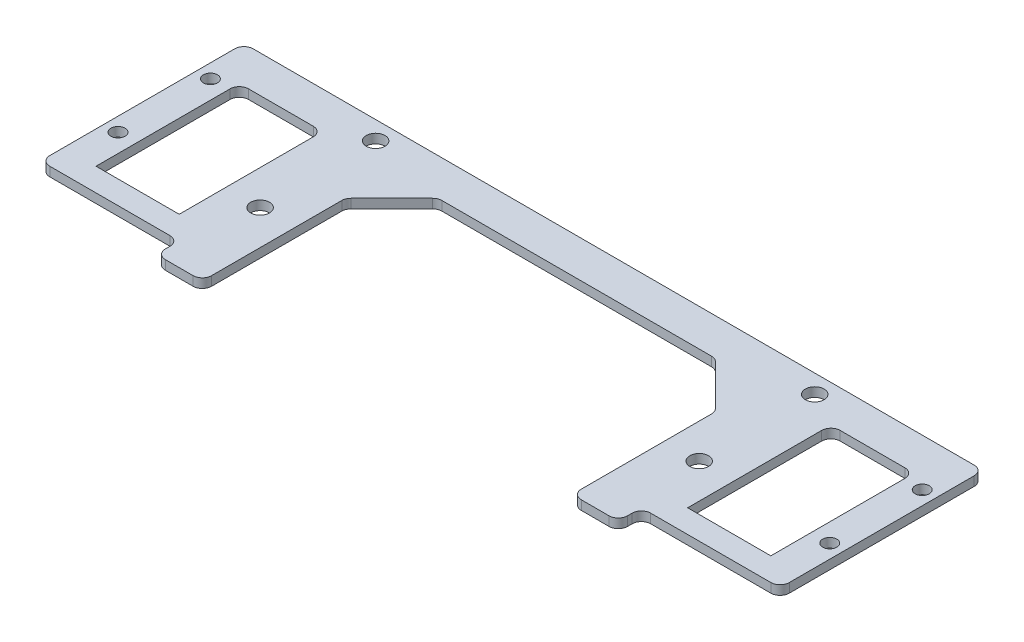
from build123d import *

# Parameters (mm, degrees)
SKETCH_1_W          = 160
SKETCH_1_H          = 49
SKETCH_1_R          = 1.525
SKETCH_1_R_2        = 2.025
EXTRUDE_1_DEPTH     = 2
SKETCH_2_W          = 80
SKETCH_2_H          = 33
SKETCH_2_W_2        = 18
CUT_EXTRUDE_1_DEPTH = 10
CHAMFER_1_SIZE      = 10
FILLET_1_R          = 2
SKETCH_3_W          = 30
SKETCH_3_H          = 5
CUT_EXTRUDE_2_DEPTH = 10
SKETCH_4_W          = 25
SKETCH_4_H          = 5
EXTRUDE_2_DEPTH     = 2
FILLET_2_R          = 2
SKETCH_5_W          = 80
SKETCH_5_H          = 18.828427125
CUT_EXTRUDE_3_DEPTH = 10
FILLET_3_R          = 2


with BuildPart() as part:
    # 草图1 → 凸台-拉伸1 (new body)
    with BuildSketch(Plane(origin=(0, 0, 0), x_dir=(1, 0, 0), z_dir=(0, 1, 0))):
        with Locations((0, -8)):
            Rectangle(SKETCH_1_W, SKETCH_1_H)
        with Locations((-77, -13.75)):
            Circle(SKETCH_1_R, mode=Mode.SUBTRACT)
        with Locations((-77, 6.25)):
            Circle(SKETCH_1_R, mode=Mode.SUBTRACT)
        with Locations((77, 6.25)):
            Circle(SKETCH_1_R, mode=Mode.SUBTRACT)
        with Locations((77, -13.75)):
            Circle(SKETCH_1_R, mode=Mode.SUBTRACT)
        with Locations((-47.5, 12.5)):
            Circle(SKETCH_1_R_2, mode=Mode.SUBTRACT)
        with Locations((-47.5, -12.5)):
            Circle(SKETCH_1_R_2, mode=Mode.SUBTRACT)
        with Locations((47.5, 12.5)):
            Circle(SKETCH_1_R_2, mode=Mode.SUBTRACT)
        with Locations((47.5, -12.5)):
            Circle(SKETCH_1_R_2, mode=Mode.SUBTRACT)
    extrude(amount=EXTRUDE_1_DEPTH)

    # 草图2 → 切除-拉伸1 (cut)
    with BuildSketch(Plane(origin=(0, 2, 0), x_dir=(1, 0, 0), z_dir=(0, 1, 0))):
        with Locations((0, -8)):
            Rectangle(SKETCH_2_W, SKETCH_2_H)
        with Locations((64, -8)):
            Rectangle(SKETCH_2_W_2, SKETCH_2_H)
        with Locations((-64, -8)):
            Rectangle(SKETCH_2_W_2, SKETCH_2_H)
    extrude(amount=-CUT_EXTRUDE_1_DEPTH, mode=Mode.SUBTRACT)

    # 倒角1
    chamfer_1_edges = [part.edges().sort_by_distance(p)[0] for p in [
        (40, 1, -8.5),
        (40, 1, 24.5),
        (-40, 1, 24.5),
        (-40, 1, -8.5),
    ]]
    chamfer(chamfer_1_edges, length=CHAMFER_1_SIZE)

    # 圆角1
    fillet_1_edges = [part.edges().sort_by_distance(p)[0] for p in [
        (30, 1, 24.5),
        (-30, 1, 24.5),
        (-40, 1, 1.5),
        (-40, 1, 14.5),
        (40, 1, 1.5),
        (40, 1, 14.5),
        (-30, 1, -8.5),
        (30, 1, -8.5),
        (73, 1, -8.5),
        (73, 1, 24.5),
        (55, 1, 24.5),
        (55, 1, -8.5),
        (-73, 1, 24.5),
        (-73, 1, -8.5),
        (-55, 1, -8.5),
        (-55, 1, 24.5),
    ]]
    fillet(fillet_1_edges, radius=FILLET_1_R)

    # 草图3 → 切除-拉伸2 (cut)
    with BuildSketch(Plane.XZ):
        with Locations((-65, 30)):
            Rectangle(SKETCH_3_W, SKETCH_3_H)
        with Locations((65, 30)):
            Rectangle(SKETCH_3_W, SKETCH_3_H)
    extrude(amount=-CUT_EXTRUDE_2_DEPTH, mode=Mode.SUBTRACT)

    # 草图4 → 凸台-拉伸2 (add)
    with BuildSketch(Plane.XZ):
        with Locations((-67.5, 25)):
            Rectangle(SKETCH_4_W, SKETCH_4_H)
        with Locations((67.5, 25)):
            Rectangle(SKETCH_4_W, SKETCH_4_H)
    extrude(amount=-EXTRUDE_2_DEPTH)

    # 圆角2
    fillet_2_edges = [part.edges().sort_by_distance(p)[0] for p in [
        (50, 1, 32.5),
        (-50, 1, 32.5),
        (-50, 1, 27.5),
        (-80, 1, 27.5),
        (80, 1, 27.5),
        (50, 1, 27.5),
        (-80, 1, -16.5),
        (80, 1, -16.5),
    ]]
    fillet(fillet_2_edges, radius=FILLET_2_R)

    # 草图5 → 切除-拉伸3 (cut)
    with BuildSketch(Plane.XZ):
        with Locations((0, 23.085786438)):
            Rectangle(SKETCH_5_W, SKETCH_5_H)
    extrude(amount=-CUT_EXTRUDE_3_DEPTH, mode=Mode.SUBTRACT)

    # 圆角3
    fillet_3_edges = [part.edges().sort_by_distance(p)[0] for p in [
        (-40, 1, 32.5),
        (40, 1, 32.5),
    ]]
    fillet(fillet_3_edges, radius=FILLET_3_R)


solid = part.part
